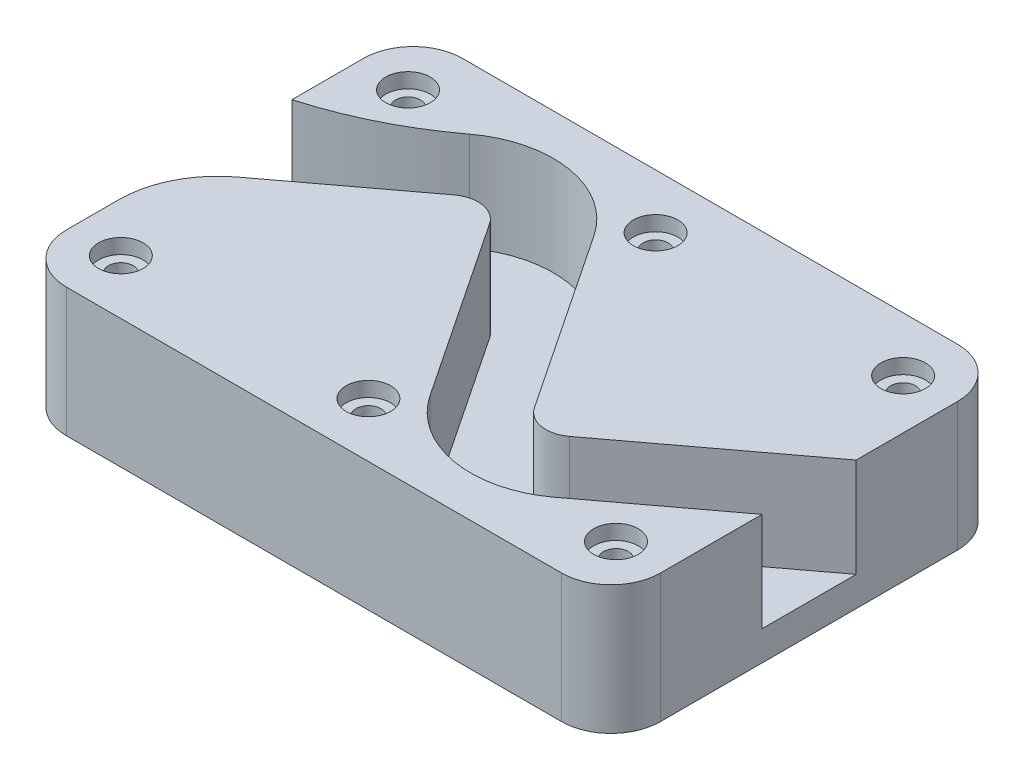
from build123d import *

# Parameters (mm, degrees)
BOSS_EXTRUDE1_DEPTH = 33.02
CUT_EXTRUDE1_DEPTH  = 25.4
SKETCH3_R           = 3.175
CUT_EXTRUDE2_DEPTH  = 34.02
SKETCH4_R           = 5.715
CUT_EXTRUDE3_DEPTH  = 3.81


with BuildPart() as part:
    # Sketch1 → Boss-Extrude1 (new body)
    with BuildSketch(Plane(origin=(0, 0, 0), x_dir=(1, 0, 0), z_dir=(0, 1, 0))):
        with BuildLine():
            Line((-63.5, -50.8), (63.5, -50.8))
            ThreePointArc((63.5, -50.8), (72.480256121, -47.080256121), (76.2, -38.1))
            Line((76.2, -38.1), (76.2, 38.1))
            ThreePointArc((76.2, 38.1), (72.480256121, 47.080256121), (63.5, 50.8))
            Line((63.5, 50.8), (-63.5, 50.8))
            ThreePointArc((-63.5, 50.8), (-72.480256121, 47.080256121), (-76.2, 38.1))
            Line((-76.2, 38.1), (-76.2, -38.1))
            ThreePointArc((-76.2, -38.1), (-72.480256121, -47.080256121), (-63.5, -50.8))
        make_face()
    extrude(amount=BOSS_EXTRUDE1_DEPTH)

    # Sketch2 → Cut-Extrude1 (cut)
    with BuildSketch(Plane(origin=(0, 33.02, 0), x_dir=(1, 0, 0), z_dir=(0, 1, 0))):
        with BuildLine():
            Line((-76.2, 19.759327566), (-76.2, -24.765))
            ThreePointArc((-76.2, -24.765), (-73.518450651, -13.405774674), (-66.04, -4.445))
            Line((-66.04, -4.445), (-34.215351473, 19.423486395))
            ThreePointArc((-34.215351473, 19.423486395), (-28.356838342, 20.838097819), (-23.30312823, 17.55430189))
            Line((-23.30312823, 17.55430189), (7.241229349, -28.262234478))
            ThreePointArc((7.241229349, -28.262234478), (25.097671742, -39.864980093), (45.797751473, -34.866686395))
            Line((45.797751473, -34.866686395), (76.2, -12.065))
            Line((76.2, -12.065), (76.2, 12.065))
            Line((76.2, 12.065), (34.215351473, -19.423486395))
            ThreePointArc((34.215351473, -19.423486395), (28.356838342, -20.838097819), (23.30312823, -17.55430189))
            Line((23.30312823, -17.55430189), (-7.241229349, 28.262234478))
            ThreePointArc((-7.241229349, 28.262234478), (-25.097671742, 39.864980093), (-45.797751473, 34.866686395))
            ThreePointArc((-45.797751473, 34.866686395), (-60.308353779, 25.923391468), (-76.2, 19.759327566))
        make_face()
    extrude(amount=-CUT_EXTRUDE1_DEPTH, mode=Mode.SUBTRACT)

    # Sketch3 → Cut-Extrude2 (cut, through all)
    with BuildSketch(Plane(origin=(0, 33.02, 0), x_dir=(1, 0, 0), z_dir=(0, 1, 0))):
        with Locations((63.5, 36.83)):
            Circle(SKETCH3_R)
        with Locations((0, 36.83)):
            Circle(SKETCH3_R)
        with Locations((-63.5, 36.83)):
            Circle(SKETCH3_R)
        with Locations((63.5, -36.83)):
            Circle(SKETCH3_R)
        with Locations((0, -36.83)):
            Circle(SKETCH3_R)
        with Locations((-63.5, -36.83)):
            Circle(SKETCH3_R)
    extrude(amount=-CUT_EXTRUDE2_DEPTH, mode=Mode.SUBTRACT)

    # Sketch4 → Cut-Extrude3 (cut)
    with BuildSketch(Plane(origin=(0, 33.02, 0), x_dir=(1, 0, 0), z_dir=(0, 1, 0))):
        with Locations((-63.5, 36.83)):
            Circle(SKETCH4_R)
        with Locations((0, 36.83)):
            Circle(SKETCH4_R)
        with Locations((63.5, 36.83)):
            Circle(SKETCH4_R)
        with Locations((63.5, -36.83)):
            Circle(SKETCH4_R)
        with Locations((0, -36.83)):
            Circle(SKETCH4_R)
        with Locations((-63.5, -36.83)):
            Circle(SKETCH4_R)
    extrude(amount=-CUT_EXTRUDE3_DEPTH, mode=Mode.SUBTRACT)


solid = part.part
